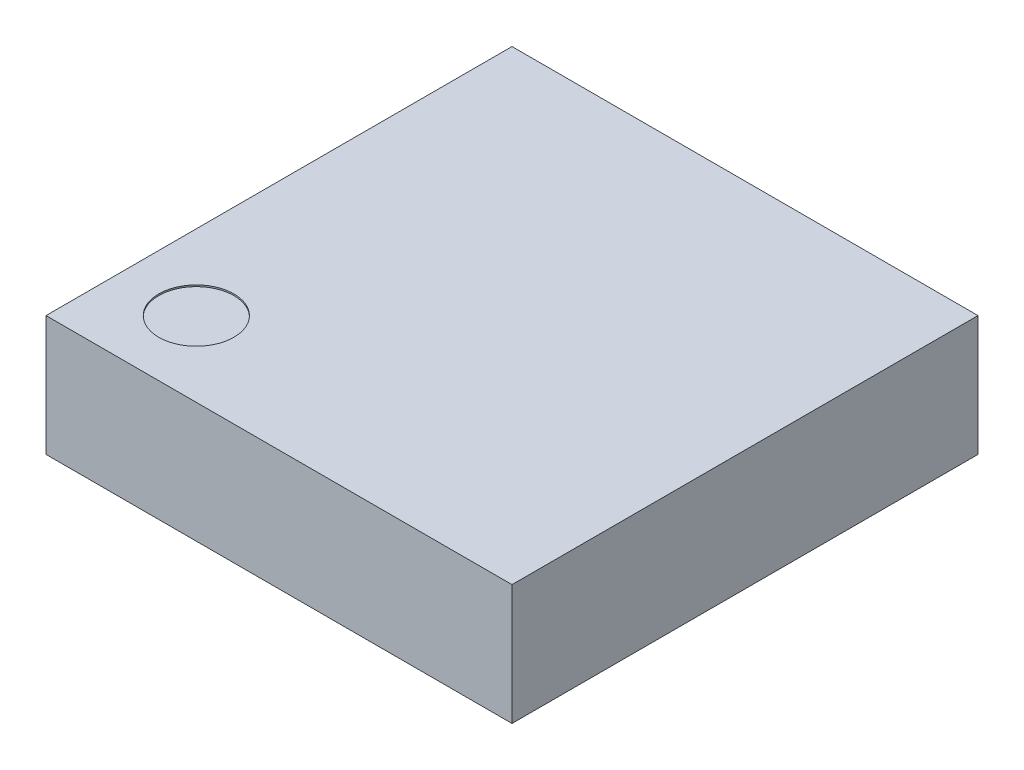
from build123d import *

# Parameters (mm, degrees)
SKETCH1_W           = 3.1
SKETCH1_H           = 3.1
BOSS_EXTRUDE1_DEPTH = 0.8
SKETCH2_R           = 0.25
CUT_EXTRUDE1_DEPTH  = 0.01


with BuildPart() as part:
    # Sketch1 → Boss-Extrude1 (new body)
    with BuildSketch(Plane(origin=(0, 0, 0), x_dir=(1, 0, 0), z_dir=(0, 1, 0))):
        Rectangle(SKETCH1_W, SKETCH1_H)
    extrude(amount=BOSS_EXTRUDE1_DEPTH)

    # Sketch2 → Cut-Extrude1 (cut)
    with BuildSketch(Plane(origin=(0, 0.8, 0), x_dir=(1, 0, 0), z_dir=(0, 1, 0))):
        with Locations((-1.05, -1.05)):
            Circle(SKETCH2_R)
    extrude(amount=-CUT_EXTRUDE1_DEPTH, mode=Mode.SUBTRACT)


solid = part.part
